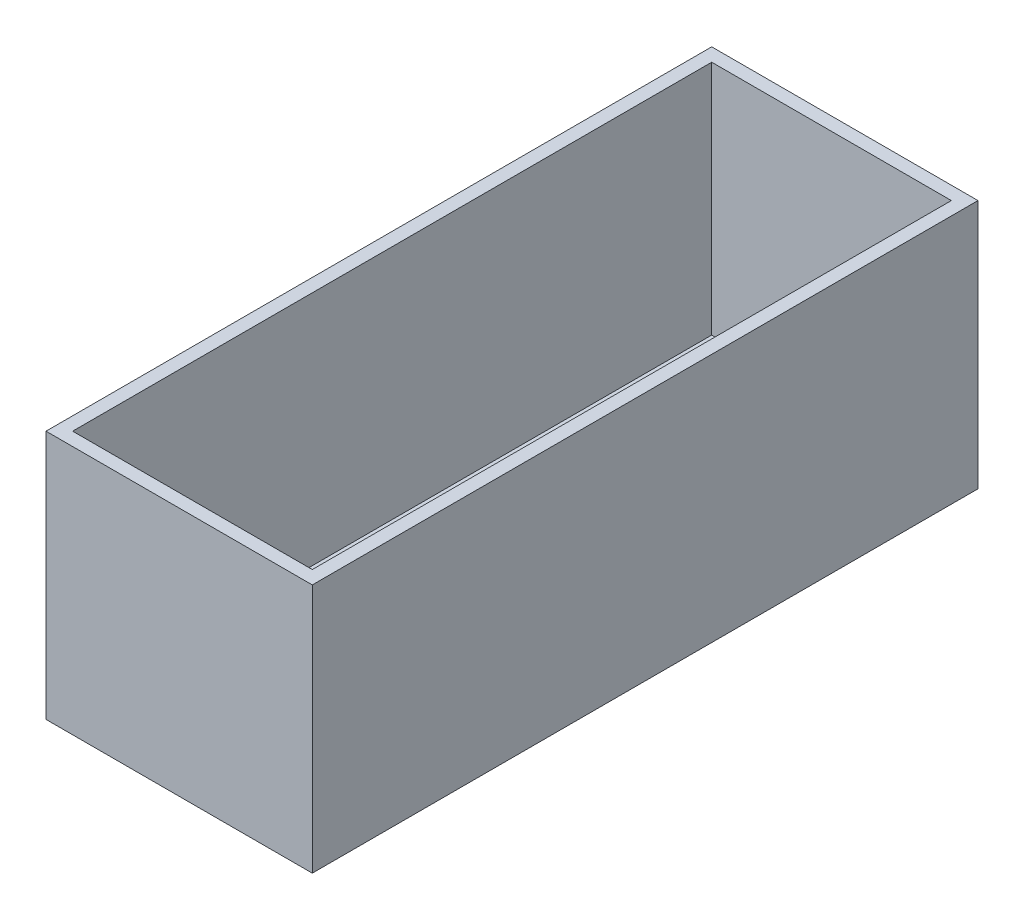
from build123d import *

# Parameters (mm, degrees)
SKETCH1_W           = 80
SKETCH1_H           = 75
BOSS_EXTRUDE1_DEPTH = 200
SHELL1_T            = -4


with BuildPart() as part:
    # Sketch1 → Boss-Extrude1 (new body)
    with BuildSketch(Plane.XY):
        with Locations((40, 37.5)):
            Rectangle(SKETCH1_W, SKETCH1_H)
    extrude(amount=-BOSS_EXTRUDE1_DEPTH)

    # Shell1
    shell1_openings = [part.faces().sort_by_distance(p)[0] for p in [
        (40, 75, -100),
    ]]
    offset(amount=SHELL1_T, openings=shell1_openings, kind=Kind.INTERSECTION)


solid = part.part
